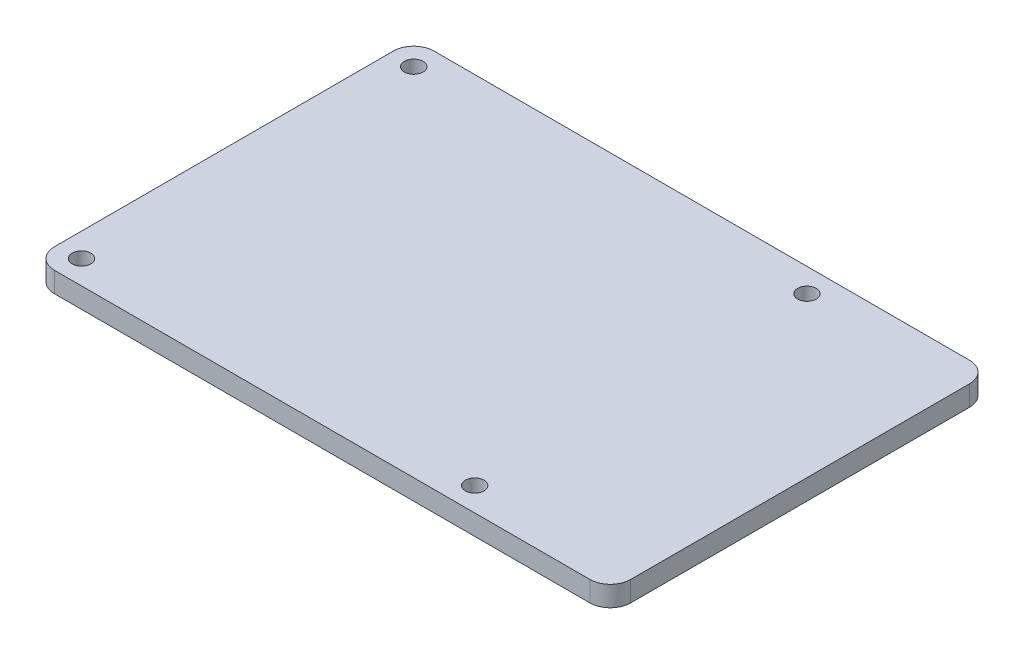
from build123d import *

# Parameters (mm, degrees)
SKETCH1_R           = 1.375
BOSS_EXTRUDE1_DEPTH = 3


with BuildPart() as part:
    # Sketch1 → Boss-Extrude1 (new body)
    with BuildSketch(Plane(origin=(0, 0, 0), x_dir=(1, 0, 0), z_dir=(0, 1, 0))):
        with BuildLine():
            Line((3, 0), (82, 0))
            ThreePointArc((82, 0), (84.121320344, 0.878679656), (85, 3))
            Line((85, 3), (85, 53))
            ThreePointArc((85, 53), (84.121320344, 55.121320344), (82, 56))
            Line((82, 56), (3, 56))
            ThreePointArc((3, 56), (0.878679656, 55.121320344), (0, 53))
            Line((0, 53), (0, 3))
            ThreePointArc((0, 3), (0.878679656, 0.878679656), (3, 0))
        make_face()
        with Locations((3.5, 52.5)):
            Circle(SKETCH1_R, mode=Mode.SUBTRACT)
        with Locations((3.5, 3.5)):
            Circle(SKETCH1_R, mode=Mode.SUBTRACT)
        with Locations((61.5, 3.5)):
            Circle(SKETCH1_R, mode=Mode.SUBTRACT)
        with Locations((61.5, 52.5)):
            Circle(SKETCH1_R, mode=Mode.SUBTRACT)
    extrude(amount=BOSS_EXTRUDE1_DEPTH)


solid = part.part
